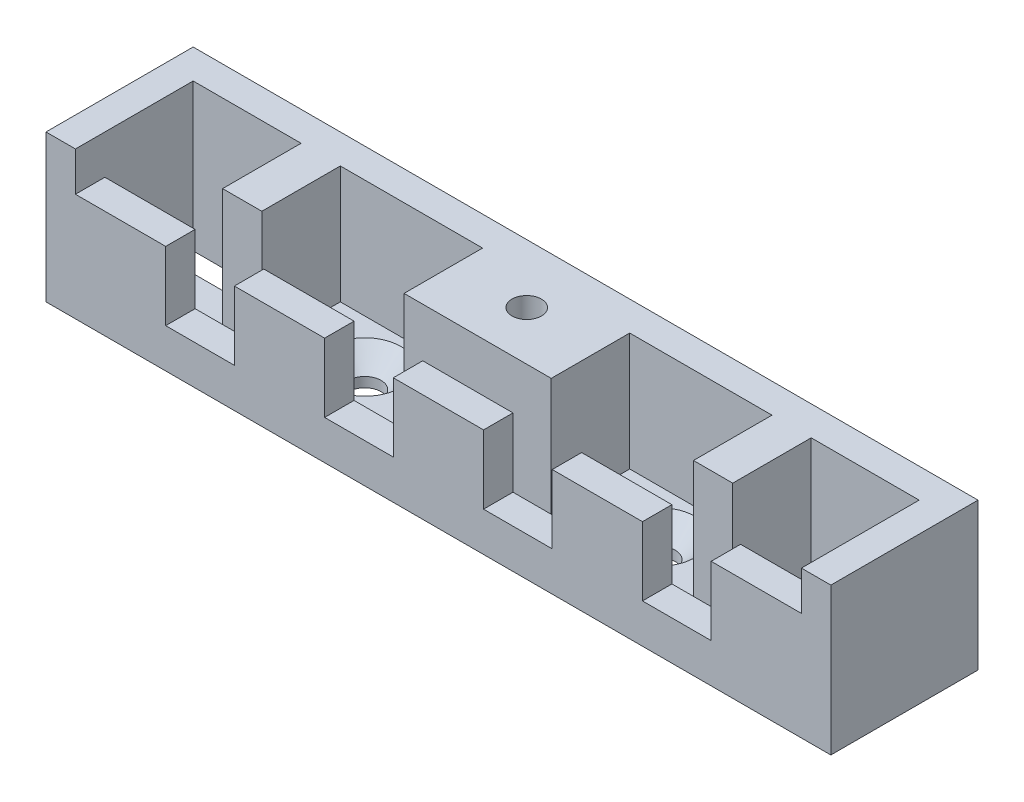
from build123d import *

# Parameters (mm, degrees)
SKETCH1_W      = 80
SKETCH1_H      = 15
SKETCH1_R      = 1.65
SKETCH1_W_2    = 10
SKETCH1_H_2    = 5
EXTRUDE1_DEPTH = 3
SKETCH2_W      = 3
SKETCH2_H      = 3
SKETCH2_H_2    = 9
SKETCH2_W_2    = 74
EXTRUDE2_DEPTH = 12
SKETCH3_W      = 7
SKETCH3_H      = 7
EXTRUDE3_DEPTH = 5
CHAMFER2_SIZE  = 2
CHAMFER3_SIZE  = 2
SKETCH4_W      = 15
SKETCH4_H      = 8
SKETCH4_W_2    = 4
EXTRUDE4_DEPTH = 12
SKETCH5_R      = 1.5
EXTRUDE5_DEPTH = 5


with BuildPart() as part:
    # Sketch1 → Extrude1 (new body)
    with BuildSketch(Plane(origin=(0, 0, 0), x_dir=(1, 0, 0), z_dir=(0, 1, 0))):
        Rectangle(SKETCH1_W, SKETCH1_H)
        with Locations((-15, 0)):
            Circle(SKETCH1_R, mode=Mode.SUBTRACT)
        with Locations((15, 0)):
            Circle(SKETCH1_R, mode=Mode.SUBTRACT)
        with Locations((-32, 2)):
            Rectangle(SKETCH1_W_2, SKETCH1_H_2, mode=Mode.SUBTRACT)
        with Locations((32, 2)):
            Rectangle(SKETCH1_W_2, SKETCH1_H_2, mode=Mode.SUBTRACT)
    extrude(amount=EXTRUDE1_DEPTH)

    # Sketch2 → Extrude2 (add)
    with BuildSketch(Plane(origin=(0, 3, 0), x_dir=(1, 0, 0), z_dir=(0, 1, 0))):
        with Locations((-38.5, 6)):
            Rectangle(SKETCH2_W, SKETCH2_H)
        with Locations((-38.5, 0)):
            Rectangle(SKETCH2_W, SKETCH2_H_2)
        with Locations((0, 6)):
            Rectangle(SKETCH2_W_2, SKETCH2_H)
        with Locations((-38.5, -6)):
            Rectangle(SKETCH2_W, SKETCH2_H)
        with Locations((0, -6)):
            Rectangle(SKETCH2_W_2, SKETCH2_H)
        with Locations((38.5, 6)):
            Rectangle(SKETCH2_W, SKETCH2_H)
        with Locations((38.5, 0)):
            Rectangle(SKETCH2_W, SKETCH2_H_2)
        with Locations((38.5, -6)):
            Rectangle(SKETCH2_W, SKETCH2_H)
    extrude(amount=EXTRUDE2_DEPTH)

    # Sketch3 → Extrude3 (cut)
    with BuildSketch(Plane.XY.offset(7.5)):
        Polygon((-20.8, 11), (-11.6, 11), (-4.6, 11), (4.6, 11), (11.6, 11), (20.8, 11), (27.8, 11), (37, 11), (37, 15), (-37, 15), (-37, 11), (-27.8, 11), align=None)
        with Locations((-24.3, 7.5)):
            Rectangle(SKETCH3_W, SKETCH3_H)
        with Locations((-8.1, 7.5)):
            Rectangle(SKETCH3_W, SKETCH3_H)
        with Locations((8.1, 7.5)):
            Rectangle(SKETCH3_W, SKETCH3_H)
        with Locations((24.3, 7.5)):
            Rectangle(SKETCH3_W, SKETCH3_H)
    extrude(amount=-EXTRUDE3_DEPTH, mode=Mode.SUBTRACT)

    # Chamfer2
    chamfer2_edges = [part.edges().sort_by_distance(p)[0] for p in [
        (13.35, 3, 0),
    ]]
    chamfer(chamfer2_edges, length=CHAMFER2_SIZE)

    # Chamfer3
    chamfer3_edges = [part.edges().sort_by_distance(p)[0] for p in [
        (-16.65, 3, 0),
    ]]
    chamfer(chamfer3_edges, length=CHAMFER3_SIZE)

    # Sketch4 → Extrude4 (add)
    with BuildSketch(Plane(origin=(0, 3, 0), x_dir=(1, 0, 0), z_dir=(0, 1, 0))):
        with Locations((0, 0.5)):
            Rectangle(SKETCH4_W, SKETCH4_H)
        with Locations((-24, 0.5)):
            Rectangle(SKETCH4_W_2, SKETCH4_H)
        with Locations((24, 0.5)):
            Rectangle(SKETCH4_W_2, SKETCH4_H)
    extrude(amount=EXTRUDE4_DEPTH)

    # Sketch5 → Extrude5 (cut)
    with BuildSketch(Plane(origin=(0, 15, 0), x_dir=(1, 0, 0), z_dir=(0, 1, 0))):
        with Locations((0, 1.5)):
            Circle(SKETCH5_R)
    extrude(amount=-EXTRUDE5_DEPTH, mode=Mode.SUBTRACT)


solid = part.part
